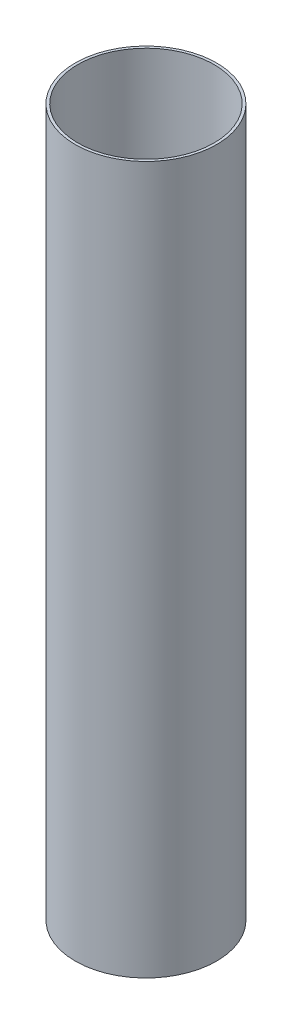
from build123d import *

# Parameters (mm, degrees)
SKETCH_1_R      = 80
SKETCH_1_R_2    = 77
EXTRUDE_1_DEPTH = 800


with BuildPart() as part:
    # Эскиз1 → Вытянуть-Тонкостенный1 (new body)
    with BuildSketch(Plane(origin=(0, 0, 0), x_dir=(1, 0, 0), z_dir=(0, 1, 0))):
        Circle(SKETCH_1_R)
        Circle(SKETCH_1_R_2, mode=Mode.SUBTRACT)
    extrude(amount=EXTRUDE_1_DEPTH)


solid = part.part
